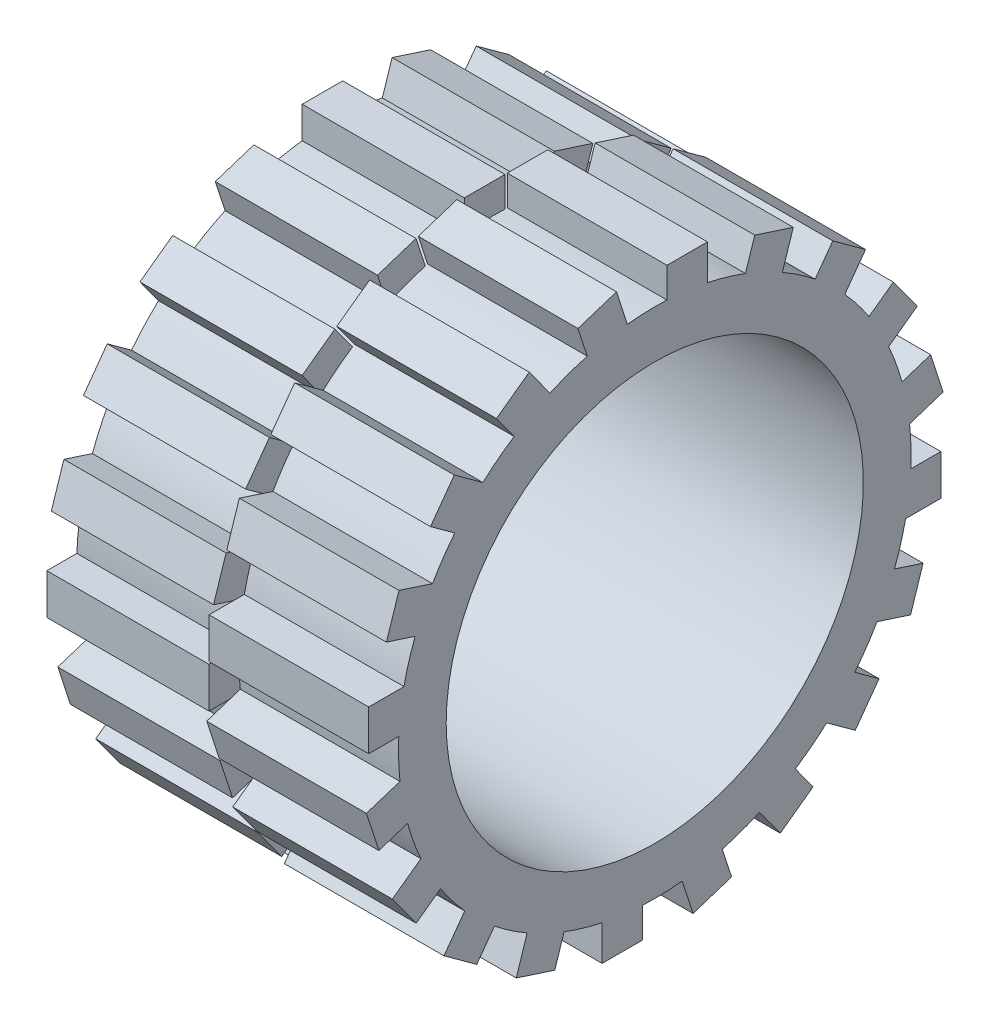
from build123d import *

# Parameters (mm, degrees)
SKETCH1_R           = 10.75
BOSS_EXTRUDE1_DEPTH = 13.5
SKETCH2_R           = 8.75
CUT_EXTRUDE1_DEPTH  = 21.331625611
SKETCH3_W           = 6.802910615
SKETCH3_H           = 1.7
SKETCH3_W_2         = 6.697089385
BOSS_EXTRUDE2_DEPTH = 2
CIRPATTERN1_COUNT   = 20
CUT_EXTRUDE5_DEPTH  = 5


with BuildPart() as part:
    # Sketch1 → Boss-Extrude1 (new body)
    with BuildSketch(Plane(origin=(0, 0, 0), x_dir=(0, 0, -1), z_dir=(1, 0, 0))):
        Circle(SKETCH1_R)
    extrude(amount=BOSS_EXTRUDE1_DEPTH)

    # Sketch2 → Cut-Extrude1 (cut, through all)
    with BuildSketch(Plane.ZY):
        Circle(SKETCH2_R)
    extrude(amount=-CUT_EXTRUDE1_DEPTH, mode=Mode.SUBTRACT)

    # Sketch3 → Boss-Extrude2 (add)
    with BuildSketch(Plane.XY.offset(10)):
        with Locations((3.401455308, -0.439203541)):
            Rectangle(SKETCH3_W, SKETCH3_H)
        with Locations((10.151455308, 1.360405179)):
            Rectangle(SKETCH3_W_2, SKETCH3_H)
    boss_extrude2 = extrude(amount=BOSS_EXTRUDE2_DEPTH)

    # CirPattern1: Boss-Extrude2 ×20 about axis
    cirpattern1_axis = Axis((0, 0, 0), (1, 0, 0))
    for i in range(1, CIRPATTERN1_COUNT):
        add(boss_extrude2.rotate(cirpattern1_axis, i * 360 / CIRPATTERN1_COUNT))

    # Sketch5 → Cut-Extrude5 (cut)
    with BuildSketch(Plane.ZY):
        with BuildLine():
            Line((-1.694575387, 9.717569944), (-1.763806157, 9.651944944))
            add(Edge.make_bspline(
                [(-1.763806157, 9.651944944), (-1.776333871, 9.663730023), (-1.801090568, 9.687019159), (-1.841451774, 9.717236272), (-1.883562422, 9.743121841), (-1.927202779, 9.764183445), (-1.971292121, 9.78098844), (-2.015245235, 9.792952819), (-2.058611272, 9.8005829), (-2.087454272, 9.801495338), (-2.101666733, 9.801944944)],
                knots=[0, 0, 0, 0, 1.08915593, 2.152340314, 3.188132944, 4.216796309, 5.218260357, 6.173443236, 7.099959455, 8, 8, 8, 8], degree=3))
            add(Edge.make_bspline(
                [(-2.101666733, 9.801944944), (-2.110387656, 9.801838588), (-2.127806884, 9.801626152), (-2.153681098, 9.798914783), (-2.179283948, 9.795015246), (-2.204567101, 9.789373049), (-2.229579718, 9.782222148), (-2.254234804, 9.773277315), (-2.278578353, 9.762848823), (-2.302381059, 9.750798473), (-2.325457189, 9.737560798), (-2.347251803, 9.722891173), (-2.36790382, 9.70725977), (-2.387025073, 9.690275233), (-2.404725549, 9.67209141), (-2.421426559, 9.65304656), (-2.436540721, 9.632620361), (-2.450192735, 9.611188629), (-2.462371437, 9.58912778), (-2.473122233, 9.566650154), (-2.482147199, 9.543830306), (-2.489287916, 9.5206396), (-2.495179227, 9.497257448), (-2.499323754, 9.473521949), (-2.50166034, 9.449407687), (-2.502064512, 9.43325982), (-2.502267695, 9.425142059)],
                knots=[0, 0, 0, 0, 1.02818874, 2.053710826, 3.065248034, 4.081641283, 5.106893873, 6.131558223, 7.173050175, 8.228653731, 9.27666206, 10.308777013, 11.325269123, 12.329503258, 13.32196095, 14.316845687, 15.314881793, 16.315733098, 17.311955233, 18.285320748, 19.252783886, 20.203351036, 21.145449891, 22.095197417, 23.042428769, 24, 24, 24, 24], degree=3))
            add(Edge.make_bspline(
                [(-2.502267695, 9.425142059), (-2.502073367, 9.416843849), (-2.501685243, 9.400270089), (-2.499201161, 9.37553447), (-2.494591042, 9.351166224), (-2.488427917, 9.327085275), (-2.480718564, 9.303250383), (-2.47110845, 9.27976488), (-2.459725867, 9.256629637), (-2.446550754, 9.234053107), (-2.432102873, 9.212061472), (-2.415917509, 9.191346167), (-2.398724788, 9.171631338), (-2.379898356, 9.153354713), (-2.360041902, 9.136027426), (-2.338562174, 9.120126863), (-2.315881542, 9.105346748), (-2.291965401, 9.091873357), (-2.267073257, 9.079836877), (-2.241550092, 9.069133589), (-2.215314368, 9.060318903), (-2.188503962, 9.053134819), (-2.161150835, 9.047246171), (-2.133116143, 9.043457819), (-2.104606018, 9.040708748), (-2.085387513, 9.040507747), (-2.075705195, 9.040406482)],
                knots=[0, 0, 0, 0, 0.93586088, 1.869166235, 2.799637598, 3.729985548, 4.670839027, 5.622275134, 6.589130586, 7.576015415, 8.568469353, 9.55398029, 10.53834874, 11.515998671, 12.510579167, 13.508179873, 14.527009472, 15.561807829, 16.601455013, 17.643573243, 18.680854198, 19.719860599, 20.772568776, 21.833555941, 22.908541556, 24, 24, 24, 24], degree=3))
            add(Edge.make_bspline(
                [(-2.075705195, 9.040406482), (-2.064036477, 9.040650402), (-2.041123054, 9.041129378), (-2.007440826, 9.044858024), (-1.975091465, 9.050681485), (-1.94416587, 9.059209858), (-1.914628121, 9.070087946), (-1.886369936, 9.083201046), (-1.859613796, 9.099052118), (-1.834279265, 9.116942541), (-1.810941703, 9.136874926), (-1.7898935, 9.158383501), (-1.771470374, 9.181363861), (-1.755397737, 9.205680656), (-1.742101226, 9.231535163), (-1.731187365, 9.258800679), (-1.722821661, 9.287489468), (-1.719387525, 9.30731303), (-1.71765231, 9.317329559)],
                knots=[0, 0, 0, 0, 1.13008108, 2.219097802, 3.278683437, 4.311054135, 5.322181354, 6.324827112, 7.324222904, 8.330512327, 9.32562643, 10.293043162, 11.24128371, 12.174520618, 13.111833804, 14.052305215, 15.015860969, 16, 16, 16, 16], degree=3))
            Line((-1.71765231, 9.317329559), (-2.01765231, 9.317329559))
            Line((-2.01765231, 9.317329559), (-2.01765231, 9.409637252))
            Line((-2.01765231, 9.409637252), (-1.63688308, 9.409637252))
            add(Edge.make_bspline(
                [(-1.63688308, 9.409637252), (-1.637321726, 9.392432469), (-1.638180237, 9.358759601), (-1.644202244, 9.30965296), (-1.65392649, 9.263271667), (-1.66721057, 9.219566877), (-1.684407071, 9.178600525), (-1.705331435, 9.140331017), (-1.730318552, 9.105005584), (-1.75847838, 9.072335841), (-1.790081226, 9.043194043), (-1.824273157, 9.017581088), (-1.861110663, 8.996006129), (-1.9005589, 8.978453388), (-1.942488725, 8.96475436), (-1.986997166, 8.955041669), (-2.034023863, 8.949222536), (-2.066253294, 8.948479038), (-2.082736445, 8.94809879)],
                knots=[0, 0, 0, 0, 1.140356446, 2.231883559, 3.274166699, 4.278491846, 5.25512956, 6.21435461, 7.1637429, 8.11826594, 9.068280886, 10.0076534, 10.945064095, 11.891975133, 12.864533718, 13.863980011, 14.907571808, 16, 16, 16, 16], degree=3))
            add(Edge.make_bspline(
                [(-2.082736445, 8.94809879), (-2.092896194, 8.948245136), (-2.112934494, 8.948533776), (-2.142529304, 8.950585094), (-2.171308121, 8.953742956), (-2.199266751, 8.958511702), (-2.226508039, 8.964352614), (-2.252895933, 8.971832055), (-2.278530952, 8.980489721), (-2.30345272, 8.99033718), (-2.327435032, 9.001747034), (-2.350584708, 9.014426656), (-2.373029711, 9.028310663), (-2.394617154, 9.043639166), (-2.415459514, 9.060297513), (-2.435422399, 9.078319092), (-2.454617568, 9.097648809), (-2.466641687, 9.11137484), (-2.472700387, 9.118291098)],
                knots=[0, 0, 0, 0, 1.107784379, 2.184907829, 3.233506516, 4.263428166, 5.276301166, 6.270063455, 7.25232949, 8.225834625, 9.190232166, 10.146266622, 11.1027726, 12.066435141, 13.031522626, 14.010570082, 14.99756817, 16, 16, 16, 16], degree=3))
            add(Edge.make_bspline(
                [(-2.472700387, 9.118291098), (-2.481491056, 9.129263551), (-2.498926476, 9.151026327), (-2.521369431, 9.185894884), (-2.54050122, 9.22199822), (-2.556024374, 9.259436839), (-2.568145596, 9.298175722), (-2.576838633, 9.338165368), (-2.581931936, 9.379457273), (-2.582665702, 9.40739977), (-2.583036926, 9.42153629)],
                knots=[0, 0, 0, 0, 1.023165419, 2.029347347, 3.013907458, 3.994755782, 4.975994455, 5.96558838, 6.970761222, 8, 8, 8, 8], degree=3))
            add(Edge.make_bspline(
                [(-2.583036926, 9.42153629), (-2.582900065, 9.432121898), (-2.582628082, 9.453158577), (-2.579330092, 9.484390456), (-2.574598298, 9.515067777), (-2.567643342, 9.545165463), (-2.558875731, 9.574703615), (-2.547933406, 9.603695949), (-2.53519329, 9.632159573), (-2.520385591, 9.659898567), (-2.50390673, 9.686544845), (-2.486022387, 9.711991137), (-2.466478604, 9.73577404), (-2.445594542, 9.758194749), (-2.42312103, 9.778971596), (-2.399268607, 9.798296938), (-2.37401889, 9.8161967), (-2.347292443, 9.832388944), (-2.319488182, 9.846933875), (-2.290672753, 9.859685386), (-2.260854953, 9.870223953), (-2.230258173, 9.879165782), (-2.198650816, 9.885778247), (-2.166262249, 9.890573638), (-2.132923649, 9.893854935), (-2.11038867, 9.89411883), (-2.098962407, 9.894252636)],
                knots=[0, 0, 0, 0, 1.008945113, 2.00506715, 2.99143336, 3.967273523, 4.948097931, 5.927297278, 6.919902385, 7.919676788, 8.923139349, 9.905703106, 10.883022732, 11.856032218, 12.825136022, 13.798837087, 14.781400844, 15.773989409, 16.776158564, 17.77167057, 18.775803737, 19.789618931, 20.80898985, 21.851988756, 22.910860228, 24, 24, 24, 24], degree=3))
            add(Edge.make_bspline(
                [(-2.098962407, 9.894252636), (-2.089644001, 9.894103624), (-2.071166698, 9.893808151), (-2.04367151, 9.891760098), (-2.016601306, 9.888513957), (-1.989915948, 9.884084212), (-1.963706311, 9.878050692), (-1.93789773, 9.870830561), (-1.912452792, 9.862424093), (-1.887451242, 9.852398389), (-1.862724973, 9.841018886), (-1.838136499, 9.82820972), (-1.813769836, 9.813751862), (-1.789582727, 9.797602381), (-1.765422649, 9.780038645), (-1.741671741, 9.760558319), (-1.717756698, 9.73992961), (-1.702379089, 9.725097049), (-1.694575387, 9.717569944)],
                knots=[0, 0, 0, 0, 0.985871117, 1.954866573, 2.915460327, 3.869826059, 4.81536089, 5.759505086, 6.70452669, 7.649098992, 8.607881297, 9.583363685, 10.581137262, 11.603961102, 12.659522466, 13.73993555, 14.853081303, 16, 16, 16, 16], degree=3))
        make_face()
        with BuildLine():
            Line((-1.498421541, 9.628868021), (-1.41765231, 9.628868021))
            Line((-1.41765231, 9.628868021), (-1.41765231, 9.532053117))
            add(Edge.make_bspline(
                [(-1.41765231, 9.532053117), (-1.411689487, 9.541067473), (-1.400285633, 9.558307358), (-1.38133088, 9.581108036), (-1.361915737, 9.599986191), (-1.34194726, 9.615029953), (-1.321278606, 9.626296183), (-1.30036339, 9.634548678), (-1.278872555, 9.639428559), (-1.264430917, 9.640080071), (-1.25719558, 9.640406482)],
                knots=[0, 0, 0, 0, 1.2804753, 2.448899062, 3.506932113, 4.484331642, 5.4025378, 6.288909075, 7.142734305, 8, 8, 8, 8], degree=3))
            add(Edge.make_bspline(
                [(-1.25719558, 9.640406482), (-1.251583096, 9.640100347), (-1.240035045, 9.639470454), (-1.222553808, 9.635044813), (-1.204542634, 9.627979036), (-1.192934592, 9.621334407), (-1.18688308, 9.617870425)],
                knots=[0, 0, 0, 0, 0.901110191, 1.854092781, 2.881294221, 4, 4, 4, 4], degree=3))
            Line((-1.18688308, 9.617870425), (-1.231234041, 9.547918502))
            add(Edge.make_bspline(
                [(-1.231234041, 9.547918502), (-1.235119218, 9.549651713), (-1.242494028, 9.55294168), (-1.253282345, 9.55683534), (-1.263228974, 9.559128004), (-1.269565889, 9.559475331), (-1.272520099, 9.559637252)],
                knots=[0, 0, 0, 0, 1.180555205, 2.24091978, 3.179933427, 4, 4, 4, 4], degree=3))
            add(Edge.make_bspline(
                [(-1.272520099, 9.559637252), (-1.279001573, 9.559205242), (-1.292221902, 9.558324068), (-1.311632202, 9.551396946), (-1.330467198, 9.540204741), (-1.345425625, 9.527792169), (-1.357007919, 9.515822736), (-1.365272548, 9.505370289), (-1.372853826, 9.49365007), (-1.380097597, 9.480862437), (-1.386697501, 9.466789048), (-1.392857273, 9.451570507), (-1.398426695, 9.435189189), (-1.401602472, 9.423776541), (-1.403229233, 9.417930521)],
                knots=[0, 0, 0, 0, 1.125678352, 2.296057538, 3.5422874, 4.923748041, 5.663163013, 6.437101912, 7.23742474, 8.08941207, 8.991984279, 9.93940061, 10.944477711, 12, 12, 12, 12], degree=3))
            add(Edge.make_bspline(
                [(-1.403229233, 9.417930521), (-1.404446135, 9.412716391), (-1.407141478, 9.401167488), (-1.409762159, 9.381792153), (-1.412351464, 9.358900355), (-1.414176309, 9.332428374), (-1.415867805, 9.302442317), (-1.416821826, 9.268896503), (-1.417619777, 9.231756498), (-1.417641137, 9.205791664), (-1.41765231, 9.192209367)],
                knots=[0, 0, 0, 0, 0.566838948, 1.255505196, 2.06880316, 3.007127437, 4.065329342, 5.249902469, 6.561414163, 8, 8, 8, 8], degree=3))
            Line((-1.41765231, 9.192209367), (-1.41765231, 8.971175713))
            Line((-1.41765231, 8.971175713), (-1.498421541, 8.971175713))
            Line((-1.498421541, 8.971175713), (-1.498421541, 9.628868021))
        make_face()
        with BuildLine():
            add(Edge.make_bspline(
                [(-0.78844558, 9.640406482), (-0.776104967, 9.64014371), (-0.75190804, 9.639628479), (-0.716471727, 9.634121773), (-0.682645835, 9.625701022), (-0.650300814, 9.614059764), (-0.619850909, 9.598455834), (-0.590852589, 9.579836301), (-0.563385359, 9.55777792), (-0.546922294, 9.540714417), (-0.538565772, 9.532053117)],
                knots=[0, 0, 0, 0, 1.054011418, 2.066658804, 3.057071809, 4.030435133, 4.997543892, 5.974964718, 6.972108034, 8, 8, 8, 8], degree=3))
            add(Edge.make_bspline(
                [(-0.538565772, 9.532053117), (-0.531370412, 9.523769521), (-0.517118943, 9.507362638), (-0.498844901, 9.480759767), (-0.483102214, 9.453209455), (-0.470486024, 9.424345857), (-0.460538447, 9.394420941), (-0.453475839, 9.363331853), (-0.449274913, 9.331147249), (-0.448708436, 9.309289119), (-0.448421541, 9.298218982)],
                knots=[0, 0, 0, 0, 1.025258237, 2.030674902, 3.01204498, 3.988269485, 4.97094183, 5.956517959, 6.965070386, 8, 8, 8, 8], degree=3))
            add(Edge.make_bspline(
                [(-0.448421541, 9.298218982), (-0.448673885, 9.287084682), (-0.449172528, 9.265082785), (-0.453889458, 9.232677805), (-0.461226023, 9.201256279), (-0.471725639, 9.170949758), (-0.485189153, 9.141665602), (-0.501618186, 9.113531718), (-0.521128031, 9.086492598), (-0.543243344, 9.06077784), (-0.567685255, 9.037077956), (-0.594200836, 9.016422115), (-0.622269016, 8.998725152), (-0.652263022, 8.984470074), (-0.683908947, 8.973230436), (-0.71727505, 8.965336146), (-0.752309497, 8.960563142), (-0.776230782, 8.959950223), (-0.78844558, 8.959637252)],
                knots=[0, 0, 0, 0, 0.998656419, 1.973391657, 2.932242238, 3.890759089, 4.846373663, 5.82037756, 6.809684879, 7.83454468, 8.860553229, 9.859544525, 10.845671541, 11.83227036, 12.833544569, 13.85385346, 14.904124723, 16, 16, 16, 16], degree=3))
            add(Edge.make_bspline(
                [(-0.78844558, 8.959637252), (-0.800720222, 8.959951274), (-0.824760729, 8.960566301), (-0.859918838, 8.965317603), (-0.89334474, 8.973226798), (-0.925032094, 8.98450701), (-0.955155055, 8.998725607), (-0.983385868, 9.016368613), (-1.009922989, 9.037084082), (-1.034370071, 9.06077618), (-1.056483998, 9.086493026), (-1.0759942, 9.113531607), (-1.092423141, 9.141665631), (-1.10588668, 9.17094975), (-1.116386289, 9.201256281), (-1.123722855, 9.232677804), (-1.128439785, 9.265082785), (-1.128938428, 9.287084682), (-1.129190772, 9.298218982)],
                knots=[0, 0, 0, 0, 1.099876186, 2.154163076, 3.173186993, 4.173200201, 5.163417411, 6.152872554, 7.150605724, 8.17532212, 9.198891216, 10.186952605, 11.159729845, 12.11414092, 13.071450619, 14.029093627, 15.002601286, 16, 16, 16, 16], degree=3))
            add(Edge.make_bspline(
                [(-1.129190772, 9.298218982), (-1.128901921, 9.309228951), (-1.128330045, 9.331026798), (-1.124133343, 9.363150899), (-1.117098285, 9.394187371), (-1.107138783, 9.423996779), (-1.094406306, 9.452733891), (-1.078884832, 9.480352276), (-1.060424383, 9.506834853), (-1.046229596, 9.523220531), (-1.039046541, 9.531512252)],
                knots=[0, 0, 0, 0, 1.031353054, 2.041901799, 3.029428768, 4.008703097, 4.981709435, 5.96992636, 6.972712378, 8, 8, 8, 8], degree=3))
            add(Edge.make_bspline(
                [(-1.039046541, 9.531512252), (-1.030702618, 9.540248665), (-1.014292824, 9.557430358), (-0.986688866, 9.579424436), (-0.957761883, 9.598431426), (-0.926975474, 9.61372531), (-0.894657024, 9.6257695), (-0.860657791, 9.63414349), (-0.825101229, 9.639608638), (-0.800785898, 9.640137884), (-0.78844558, 9.640406482)],
                knots=[0, 0, 0, 0, 1.027980169, 2.021703884, 2.998553061, 3.971491411, 4.943284454, 5.930300938, 6.949603206, 8, 8, 8, 8], degree=3))
        make_face()
        with BuildLine():
            add(Edge.make_bspline(
                [(-0.788806157, 9.559637252), (-0.797532971, 9.559389214), (-0.814761318, 9.558899541), (-0.84012064, 9.555175109), (-0.864533823, 9.549274322), (-0.888047182, 9.540890422), (-0.910581427, 9.53006499), (-0.93215813, 9.516768555), (-0.952840758, 9.501177223), (-0.972224717, 9.483315393), (-0.990014454, 9.463803652), (-1.005565934, 9.443014074), (-1.018789533, 9.421283871), (-1.029805574, 9.398590445), (-1.038010279, 9.374703824), (-1.043969056, 9.349894519), (-1.047689975, 9.324111983), (-1.048175044, 9.306584864), (-1.048421541, 9.297678117)],
                knots=[0, 0, 0, 0, 1.021534396, 2.016698045, 2.994645724, 3.958388632, 4.93408049, 5.916473867, 6.921342795, 7.962252576, 8.998418191, 10.008913653, 10.997312074, 11.973003931, 12.956656626, 13.948281152, 14.957379055, 16, 16, 16, 16], degree=3))
            add(Edge.make_bspline(
                [(-1.048421541, 9.297678117), (-1.048008358, 9.286170453), (-1.047188267, 9.263329892), (-1.040519206, 9.229692746), (-1.029362734, 9.197400269), (-1.014297433, 9.16664177), (-0.995421548, 9.138183184), (-0.973182017, 9.112810517), (-0.947817523, 9.090905594), (-0.919630423, 9.072730519), (-0.889196455, 9.058289439), (-0.856987687, 9.048055417), (-0.823394366, 9.041402696), (-0.800436463, 9.04074146), (-0.788806157, 9.040406482)],
                knots=[0, 0, 0, 0, 1.016792936, 2.018143844, 3.017858371, 4.030088057, 5.03801393, 6.028138512, 7.003788237, 7.991172063, 8.984598303, 9.972568034, 10.972917682, 12, 12, 12, 12], degree=3))
            add(Edge.make_bspline(
                [(-0.788806157, 9.040406482), (-0.777176519, 9.040743412), (-0.754219937, 9.041408501), (-0.720673292, 9.048021911), (-0.688552556, 9.058334281), (-0.658150199, 9.072714278), (-0.62997593, 9.090974613), (-0.604429013, 9.112686825), (-0.58237937, 9.138250386), (-0.563522157, 9.166679465), (-0.548210138, 9.197352584), (-0.537105886, 9.229698706), (-0.530420792, 9.263328374), (-0.529602865, 9.286169944), (-0.529190772, 9.297678117)],
                knots=[0, 0, 0, 0, 1.02726834, 2.027799167, 3.010890988, 4.004497153, 4.992059811, 5.971914811, 6.958719428, 7.966827853, 8.981595046, 9.981490638, 10.983022906, 12, 12, 12, 12], degree=3))
            add(Edge.make_bspline(
                [(-0.529190772, 9.297678117), (-0.529437184, 9.306584918), (-0.529922086, 9.324112141), (-0.53364422, 9.349893915), (-0.539598501, 9.37470604), (-0.547819774, 9.398582269), (-0.558787949, 9.421342628), (-0.572266553, 9.442950272), (-0.587754531, 9.463875669), (-0.605758934, 9.48325232), (-0.625122659, 9.501184186), (-0.645813669, 9.516774601), (-0.667358378, 9.530006554), (-0.689827156, 9.540983016), (-0.713343531, 9.549198046), (-0.737722507, 9.55520918), (-0.76297363, 9.558883802), (-0.780140241, 9.559384495), (-0.788806157, 9.559637252)],
                knots=[0, 0, 0, 0, 1.042956736, 2.052379634, 3.044323526, 4.02829302, 5.004299113, 5.996692471, 7.007513377, 8.048758398, 9.090003419, 10.095195979, 11.07790575, 12.047570684, 13.018257071, 13.989683339, 14.985167495, 16, 16, 16, 16], degree=3))
        make_face(mode=Mode.SUBTRACT)
        with BuildLine():
            Line((-0.298421541, 9.628868021), (-0.21765231, 9.628868021))
            Line((-0.21765231, 9.628868021), (-0.21765231, 9.323819944))
            add(Edge.make_bspline(
                [(-0.21765231, 9.323819944), (-0.217615821, 9.314865523), (-0.217546017, 9.297736134), (-0.217072632, 9.273087658), (-0.21595918, 9.250609075), (-0.214567053, 9.230287399), (-0.21277679, 9.21212607), (-0.210646783, 9.196188521), (-0.208266046, 9.182294017), (-0.205935634, 9.173925725), (-0.20485183, 9.170033886)],
                knots=[0, 0, 0, 0, 1.388932606, 2.656963016, 3.823490214, 4.879454478, 5.816252168, 6.653371382, 7.373723809, 8, 8, 8, 8], degree=3))
            add(Edge.make_bspline(
                [(-0.20485183, 9.170033886), (-0.20311317, 9.165142291), (-0.199671996, 9.155460795), (-0.193430243, 9.141475051), (-0.185708671, 9.128521407), (-0.177259001, 9.11610036), (-0.167513439, 9.104579849), (-0.156595289, 9.093979329), (-0.144870029, 9.083898277), (-0.127447308, 9.071970759), (-0.10362064, 9.059186817), (-0.072338503, 9.048156464), (-0.038420273, 9.041564396), (-0.014977917, 9.040799587), (-0.002928753, 9.040406482)],
                knots=[0, 0, 0, 0, 0.725840625, 1.436591201, 2.137033971, 2.831655856, 3.53531722, 4.242432219, 4.957935707, 5.694543706, 7.190802206, 8.724350549, 10.316345118, 12, 12, 12, 12], degree=3))
            add(Edge.make_bspline(
                [(-0.002928753, 9.040406482), (0.009119292, 9.040807946), (0.03243003, 9.041584705), (0.065975593, 9.047957615), (0.096640243, 9.058604792), (0.124116202, 9.073469555), (0.148278846, 9.091660371), (0.168414268, 9.113005493), (0.185027562, 9.136829621), (0.192281413, 9.154604436), (0.19592942, 9.163543502)],
                knots=[0, 0, 0, 0, 1.157059328, 2.238695713, 3.266970494, 4.264342957, 5.228770407, 6.160125903, 7.074715775, 8, 8, 8, 8], degree=3))
            add(Edge.make_bspline(
                [(0.19592942, 9.163543502), (0.197007937, 9.167134836), (0.199392273, 9.175074398), (0.20195402, 9.188543476), (0.204261739, 9.204605803), (0.20623227, 9.223366485), (0.207637598, 9.244776496), (0.208395147, 9.268829144), (0.209250989, 9.295448922), (0.209263979, 9.314083489), (0.209270767, 9.323819944)],
                knots=[0, 0, 0, 0, 0.557542046, 1.232589297, 2.036731608, 2.971723315, 4.038036528, 5.22795436, 6.551621927, 8, 8, 8, 8], degree=3))
            Line((0.209270767, 9.323819944), (0.209270767, 9.628868021))
            Line((0.209270767, 9.628868021), (0.290039997, 9.628868021))
            Line((0.290039997, 9.628868021), (0.290039997, 9.308675713))
            add(Edge.make_bspline(
                [(0.290039997, 9.308675713), (0.289926419, 9.297796726), (0.28970606, 9.276690003), (0.288289886, 9.246016946), (0.285859986, 9.217432369), (0.282171867, 9.190921141), (0.277834979, 9.166503503), (0.272240509, 9.14414816), (0.265560391, 9.123923989), (0.258024687, 9.105476103), (0.249121921, 9.088749759), (0.239652116, 9.072874835), (0.228717174, 9.058245223), (0.217204828, 9.044132673), (0.204398688, 9.031239137), (0.190538725, 9.019268758), (0.175820017, 9.00803855), (0.159915937, 8.997986507), (0.143058664, 8.988930798), (0.125227386, 8.980903806), (0.106203701, 8.974551715), (0.086233052, 8.96907183), (0.065217594, 8.964773823), (0.043177588, 8.961742992), (0.020120459, 8.959885049), (0.004406597, 8.959721238), (-0.003649907, 8.959637252)],
                knots=[0, 0, 0, 0, 1.493040784, 2.896703357, 4.213163133, 5.428574705, 6.569057535, 7.615249723, 8.588095153, 9.490268104, 10.346124644, 11.18633936, 12.024365274, 12.850166724, 13.684164916, 14.514361689, 15.362232829, 16.222528818, 17.093394965, 17.986930858, 18.902426812, 19.842810585, 20.827885679, 21.843828298, 22.894529745, 24, 24, 24, 24], degree=3))
            add(Edge.make_bspline(
                [(-0.003649907, 8.959637252), (-0.011646153, 8.959724605), (-0.027359522, 8.959896262), (-0.050417842, 8.961732727), (-0.072518912, 8.964769114), (-0.093584157, 8.969103313), (-0.113634717, 8.974513359), (-0.132751807, 8.98094284), (-0.15071158, 8.988934964), (-0.16772981, 8.997929193), (-0.183673281, 9.008103121), (-0.198615487, 9.019254902), (-0.212536392, 9.03136789), (-0.225439066, 9.044391496), (-0.237142403, 9.05848728), (-0.247792243, 9.073541852), (-0.257552538, 9.089406046), (-0.266386113, 9.106393717), (-0.27397485, 9.125055091), (-0.28067477, 9.145702916), (-0.286154649, 9.168563563), (-0.290614141, 9.193617487), (-0.294201654, 9.220744784), (-0.296692376, 9.250102376), (-0.298085018, 9.281618754), (-0.298306948, 9.303385869), (-0.298421541, 9.314625232)],
                knots=[0, 0, 0, 0, 1.083640291, 2.129454052, 3.13281866, 4.105697902, 5.042300162, 5.946461698, 6.836384745, 7.703652036, 8.553297018, 9.397182691, 10.228592656, 11.052265423, 11.879314572, 12.708807002, 13.549817954, 14.402308542, 15.300838682, 16.27712199, 17.341985831, 18.484375296, 19.725102775, 21.0496083, 22.476576903, 24, 24, 24, 24], degree=3))
            Line((-0.298421541, 9.314625232), (-0.298421541, 9.628868021))
        make_face()
        with BuildLine():
            Line((0.474655382, 9.628868021), (0.555424613, 9.628868021))
            Line((0.555424613, 9.628868021), (0.555424613, 9.507173309))
            add(Edge.make_bspline(
                [(0.555424613, 9.507173309), (0.564002251, 9.518214441), (0.580671176, 9.539670671), (0.609400437, 9.567439561), (0.639724474, 9.590858925), (0.672423637, 9.609214433), (0.706989729, 9.62305407), (0.743280896, 9.633283072), (0.78160515, 9.63931088), (0.807807095, 9.64003645), (0.821169805, 9.640406482)],
                knots=[0, 0, 0, 0, 1.0828784, 2.104357462, 3.088488658, 4.04616522, 5.001424249, 5.969181776, 6.964304535, 8, 8, 8, 8], degree=3))
            add(Edge.make_bspline(
                [(0.821169805, 9.640406482), (0.832841932, 9.640068808), (0.855912503, 9.639401376), (0.889871619, 9.634882591), (0.92257386, 9.627138041), (0.953834217, 9.615977806), (0.983987577, 9.602180685), (1.012587545, 9.584767733), (1.040079602, 9.564606141), (1.065772337, 9.541403588), (1.089512117, 9.516299177), (1.110043992, 9.489293441), (1.12775391, 9.461274491), (1.142069129, 9.431807953), (1.153282704, 9.401125865), (1.161257907, 9.369104266), (1.166004158, 9.335861881), (1.16664096, 9.313258325), (1.166963074, 9.301824752)],
                knots=[0, 0, 0, 0, 1.041296284, 2.058176809, 3.050446431, 4.034000596, 5.01514041, 6.003636468, 7.015969324, 8.052561599, 9.08815499, 10.094063707, 11.074456064, 12.040834395, 13.011057502, 13.983766392, 14.980127149, 16, 16, 16, 16], degree=3))
            add(Edge.make_bspline(
                [(1.166963074, 9.301824752), (1.166647949, 9.290149872), (1.166026478, 9.267125325), (1.161206333, 9.233314358), (1.153503137, 9.200789033), (1.142431033, 9.169603451), (1.128123222, 9.139779083), (1.110713477, 9.111337439), (1.090171243, 9.084287629), (1.06669381, 9.058996884), (1.041223055, 9.035699917), (1.013997415, 9.015324414), (0.985439406, 8.998213774), (0.955695134, 8.983921013), (0.92450997, 8.973148737), (0.892029413, 8.965378446), (0.858271147, 8.960586718), (0.835307993, 8.959956167), (0.823693843, 8.959637252)],
                knots=[0, 0, 0, 0, 1.038740735, 2.04854663, 3.033179607, 4.009277356, 4.987731542, 5.972001279, 6.972200261, 8.005528982, 9.039189865, 10.040446548, 11.026516639, 11.997840187, 12.972163198, 13.956796175, 14.96660207, 16, 16, 16, 16], degree=3))
            add(Edge.make_bspline(
                [(0.823693843, 8.959637252), (0.810623896, 8.959970202), (0.784806919, 8.960627877), (0.747058947, 8.967292868), (0.710730613, 8.977253795), (0.676224401, 8.991833536), (0.643266964, 9.010413526), (0.612044728, 9.033070436), (0.582391849, 9.059756882), (0.564543883, 9.080002206), (0.555424613, 9.090346386)],
                knots=[0, 0, 0, 0, 1.014726462, 2.004382257, 2.969841629, 3.936926163, 4.907207904, 5.903978561, 6.929055279, 8, 8, 8, 8], degree=3))
            Line((0.555424613, 9.090346386), (0.555424613, 8.728868021))
            Line((0.555424613, 8.728868021), (0.474655382, 8.728868021))
            Line((0.474655382, 8.728868021), (0.474655382, 9.628868021))
        make_face()
        with BuildLine():
            add(Edge.make_bspline(
                [(0.820448651, 9.559637252), (0.811299621, 9.559472614), (0.793287538, 9.559148484), (0.76688611, 9.55529804), (0.741455858, 9.549708336), (0.71725307, 9.541245275), (0.694045769, 9.530857009), (0.672012698, 9.517875921), (0.651169323, 9.502536833), (0.631568087, 9.485133574), (0.613860383, 9.465957225), (0.598184201, 9.445491789), (0.585016609, 9.423763181), (0.574087518, 9.400973802), (0.565770674, 9.376945015), (0.559867774, 9.351813669), (0.556157112, 9.325552257), (0.555671385, 9.307666427), (0.555424613, 9.298579559)],
                knots=[0, 0, 0, 0, 1.05670511, 2.080379991, 3.077984906, 4.06214886, 5.038337365, 6.01289324, 7.01187578, 8.025460281, 9.038092164, 10.024533457, 11.000252242, 11.969694649, 12.940728589, 13.933144304, 14.949937299, 16, 16, 16, 16], degree=3))
            add(Edge.make_bspline(
                [(0.555424613, 9.298579559), (0.55583369, 9.286651188), (0.556635107, 9.263282497), (0.56315043, 9.229138008), (0.573753784, 9.196827583), (0.588804024, 9.166623316), (0.607819115, 9.138856301), (0.630730069, 9.113993003), (0.657329583, 9.092189708), (0.687175432, 9.073824242), (0.719169694, 9.058913025), (0.752543214, 9.048237943), (0.786837041, 9.041662227), (0.81002318, 9.040827331), (0.82171067, 9.040406482)],
                knots=[0, 0, 0, 0, 1.03728447, 2.032128127, 3.01272805, 3.987917167, 4.958271349, 5.931593992, 6.91984656, 7.941419022, 8.973179163, 9.983609215, 10.983593296, 12, 12, 12, 12], degree=3))
            add(Edge.make_bspline(
                [(0.82171067, 9.040406482), (0.833162725, 9.040806694), (0.855892995, 9.041601041), (0.889362226, 9.048476575), (0.92188839, 9.058979581), (0.952791863, 9.074294896), (0.981803617, 9.093063768), (1.008001731, 9.115579205), (1.030889223, 9.141676619), (1.0503972, 9.170735948), (1.066116725, 9.201895333), (1.077927358, 9.234136261), (1.084743848, 9.267345084), (1.085709879, 9.289715925), (1.086193843, 9.300923309)],
                knots=[0, 0, 0, 0, 1.00104056, 1.986885549, 2.97790532, 3.984399681, 4.995088187, 5.994304198, 6.996462723, 8.023150851, 9.048424203, 10.043036403, 11.019596776, 12, 12, 12, 12], degree=3))
            add(Edge.make_bspline(
                [(1.086193843, 9.300923309), (1.085819769, 9.312200307), (1.085074535, 9.334666442), (1.077733868, 9.367776903), (1.066702445, 9.400148096), (1.050615832, 9.430881952), (1.031535505, 9.459881002), (1.008457706, 9.485480571), (0.98258497, 9.507895887), (0.953607756, 9.526414135), (0.92250879, 9.541144691), (0.889770668, 9.551914769), (0.855559456, 9.558388019), (0.832255202, 9.559217178), (0.820448651, 9.559637252)],
                knots=[0, 0, 0, 0, 0.983928682, 1.960191568, 2.949917689, 3.96440592, 4.982380491, 5.975291189, 6.965713506, 7.964880129, 8.970154049, 9.96478489, 10.968906225, 12, 12, 12, 12], degree=3))
        make_face(mode=Mode.SUBTRACT)
        with BuildLine():
            Line((2.03234769, 9.894252636), (2.094547209, 9.845394463))
            Line((2.094547209, 9.845394463), (1.856746728, 9.481752636))
            add(Edge.make_bspline(
                [(1.856746728, 9.481752636), (1.872579085, 9.4842762), (1.903461887, 9.489198698), (1.93472169, 9.490010741), (1.949955863, 9.490406482)],
                knots=[0, 0, 0, 0, 1.025318673, 2, 2, 2, 2], degree=3))
            add(Edge.make_bspline(
                [(1.949955863, 9.490406482), (1.959103076, 9.490160625), (1.977109093, 9.489676662), (2.003545128, 9.485952244), (2.028947997, 9.480082929), (2.053212412, 9.471527206), (2.076425464, 9.460598029), (2.098720366, 9.447499463), (2.119678026, 9.431555145), (2.139568329, 9.413744156), (2.157626726, 9.394016932), (2.173614854, 9.373085159), (2.187044601, 9.350970647), (2.197940752, 9.327684596), (2.206402006, 9.303262901), (2.212570258, 9.277736808), (2.216216439, 9.251088715), (2.216711565, 9.232965756), (2.216963074, 9.223759848)],
                knots=[0, 0, 0, 0, 1.04369286, 2.054478336, 3.041073146, 4.015093852, 4.984733326, 5.965804835, 6.960378782, 7.985147595, 9.009457201, 10.008161701, 10.986880575, 11.956520048, 12.937015923, 13.931873656, 14.949455224, 16, 16, 16, 16], degree=3))
            add(Edge.make_bspline(
                [(2.216963074, 9.223759848), (2.216597133, 9.211165067), (2.215877047, 9.186381518), (2.208701785, 9.150284651), (2.197552162, 9.11589629), (2.181615084, 9.083765474), (2.161819614, 9.053936242), (2.137679661, 9.027505694), (2.110051336, 9.003933399), (2.078811873, 8.984221697), (2.045192254, 8.968123769), (2.009873169, 8.956561278), (1.973197617, 8.949442672), (1.948305004, 8.948550231), (1.935713074, 8.94809879)],
                knots=[0, 0, 0, 0, 1.031375318, 2.029502543, 3.004789286, 3.987476834, 4.960371455, 5.9300674, 6.912260825, 7.929083631, 8.949397511, 9.960523116, 10.96833055, 12, 12, 12, 12], degree=3))
            add(Edge.make_bspline(
                [(1.935713074, 8.94809879), (1.923602494, 8.948491757), (1.899613555, 8.949270157), (1.864325122, 8.956204255), (1.830417489, 8.967443224), (1.79812822, 8.982926896), (1.768217205, 9.002484637), (1.74145747, 9.026029223), (1.717982442, 9.053057371), (1.698446111, 9.083564889), (1.682951009, 9.116348021), (1.671330742, 9.150531861), (1.664543137, 9.185991857), (1.663594651, 9.210029864), (1.66311692, 9.222137252)],
                knots=[0, 0, 0, 0, 1.012016664, 2.004627821, 2.994792927, 3.992885782, 4.990978636, 5.973936114, 6.964471063, 7.975201453, 8.993600317, 9.990122807, 10.98767138, 12, 12, 12, 12], degree=3))
            add(Edge.make_bspline(
                [(1.66311692, 9.222137252), (1.66342072, 9.231405859), (1.664041022, 9.250330584), (1.66837218, 9.278992762), (1.675331699, 9.308320183), (1.683125762, 9.333199833), (1.691360919, 9.353581367), (1.698214429, 9.370013693), (1.706744885, 9.386923684), (1.715840897, 9.40489119), (1.726321235, 9.423453158), (1.737716688, 9.442919816), (1.750342312, 9.462981569), (1.759193211, 9.476595791), (1.763717882, 9.483555521)],
                knots=[0, 0, 0, 0, 1.173818275, 2.396712641, 3.66331629, 4.989737886, 5.693666774, 6.447286557, 7.243889047, 8.091586357, 8.998013824, 9.943181721, 10.948533338, 12, 12, 12, 12], degree=3))
            Line((1.763717882, 9.483555521), (2.03234769, 9.894252636))
        make_face()
        with BuildLine():
            add(Edge.make_bspline(
                [(1.933008747, 9.39809879), (1.926152741, 9.397898722), (1.91276097, 9.39750793), (1.89311335, 9.39523858), (1.874518513, 9.390965106), (1.856730108, 9.385522335), (1.840080698, 9.378038691), (1.824449282, 9.368948228), (1.809775412, 9.358245639), (1.796212784, 9.346082548), (1.783916299, 9.332765625), (1.773326866, 9.318502034), (1.764192534, 9.303635524), (1.756765781, 9.288041882), (1.750982619, 9.271727068), (1.746799354, 9.254766118), (1.744471247, 9.237045296), (1.74408393, 9.225028367), (1.743886151, 9.218892059)],
                knots=[0, 0, 0, 0, 1.129588631, 2.206414736, 3.251139165, 4.268635594, 5.265702196, 6.250456724, 7.242448911, 8.251968645, 9.246821453, 10.222880186, 11.173611482, 12.116736599, 13.062300278, 14.020270554, 14.989073742, 16, 16, 16, 16], degree=3))
            add(Edge.make_bspline(
                [(1.743886151, 9.218892059), (1.744047216, 9.212810636), (1.744363039, 9.20088587), (1.747230778, 9.183312938), (1.751611228, 9.166401962), (1.75812733, 9.150240122), (1.765899958, 9.134581069), (1.776161327, 9.119991995), (1.787531358, 9.105586835), (1.801122369, 9.09247217), (1.815708377, 9.080269039), (1.831291543, 9.069602688), (1.847532676, 9.060477672), (1.864651041, 9.053326246), (1.882403769, 9.047457144), (1.900938768, 9.043327049), (1.920268931, 9.040992057), (1.933363144, 9.040604236), (1.940039997, 9.040406482)],
                knots=[0, 0, 0, 0, 0.989467248, 1.94019797, 2.891935182, 3.827694429, 4.772920941, 5.730924762, 6.725747692, 7.756678648, 8.79901574, 9.819492441, 10.826891316, 11.826466727, 12.835195252, 13.867842842, 14.912794438, 16, 16, 16, 16], degree=3))
            add(Edge.make_bspline(
                [(1.940039997, 9.040406482), (1.94671684, 9.040604251), (1.959811031, 9.040992103), (1.979141349, 9.043326875), (1.997675774, 9.047457784), (2.015430591, 9.053323925), (2.032541244, 9.060486282), (2.048768173, 9.069545919), (2.064203968, 9.080334635), (2.078799551, 9.092451316), (2.092333992, 9.105661478), (2.103976721, 9.119863407), (2.113923838, 9.13469898), (2.122006915, 9.150178437), (2.128451247, 9.166411734), (2.13285391, 9.18331032), (2.135715727, 9.200886555), (2.136032364, 9.212810867), (2.136193843, 9.218892059)],
                knots=[0, 0, 0, 0, 1.087397944, 2.132534446, 3.165364764, 4.174271784, 5.174024072, 6.181601208, 7.194203697, 8.236725232, 9.267838612, 10.269026844, 11.221737037, 12.171628256, 13.107553087, 14.05945871, 15.010357665, 16, 16, 16, 16], degree=3))
            add(Edge.make_bspline(
                [(2.136193843, 9.218892059), (2.13605234, 9.225036372), (2.135774613, 9.237095661), (2.132633369, 9.254758191), (2.128276759, 9.271813244), (2.121698265, 9.288153631), (2.113151725, 9.30371487), (2.102741706, 9.318575567), (2.090699045, 9.332849656), (2.07678825, 9.346108664), (2.061645047, 9.358232198), (2.045543896, 9.36893437), (2.028698988, 9.377966507), (2.011127403, 9.385502619), (1.992627805, 9.390941055), (1.973498861, 9.395223318), (1.953495912, 9.397502122), (1.939924785, 9.397897368), (1.933008747, 9.39809879)],
                knots=[0, 0, 0, 0, 0.978206639, 1.919901502, 2.851605144, 3.780102724, 4.718870031, 5.675451981, 6.667674623, 7.690630536, 8.733308323, 9.756129687, 10.767539656, 11.776269907, 12.797430371, 13.836405707, 14.897401972, 16, 16, 16, 16], degree=3))
        make_face(mode=Mode.SUBTRACT)
        with BuildLine():
            Line((2.505424613, 8.94809879), (2.440881343, 8.992990617))
            Line((2.440881343, 8.992990617), (2.691121728, 9.358795906))
            add(Edge.make_bspline(
                [(2.691121728, 9.358795906), (2.675155539, 9.356843404), (2.643717222, 9.352998818), (2.612053396, 9.352292536), (2.596470286, 9.351944944)],
                knots=[0, 0, 0, 0, 1.015715272, 2, 2, 2, 2], degree=3))
            add(Edge.make_bspline(
                [(2.596470286, 9.351944944), (2.587022331, 9.352186935), (2.568476821, 9.352661942), (2.541211539, 9.356426979), (2.515012395, 9.362225583), (2.489948846, 9.37087812), (2.465926688, 9.381631374), (2.442998361, 9.394966035), (2.421194732, 9.410653367), (2.40074997, 9.428610422), (2.382155523, 9.448327635), (2.365589532, 9.469196229), (2.351821812, 9.491458621), (2.340384976, 9.514660678), (2.331711431, 9.539135882), (2.32539535, 9.564605728), (2.321506744, 9.591248722), (2.32104412, 9.609383755), (2.320809228, 9.618591579)],
                knots=[0, 0, 0, 0, 1.060718605, 2.082097864, 3.085795603, 4.069760067, 5.054557537, 6.03741023, 7.043284206, 8.066802108, 9.088538119, 10.083643548, 11.053783639, 12.022749082, 12.983451788, 13.964007469, 14.966251758, 16, 16, 16, 16], degree=3))
            add(Edge.make_bspline(
                [(2.320809228, 9.618591579), (2.321255226, 9.631183518), (2.322130628, 9.65589894), (2.329175961, 9.692010481), (2.340762906, 9.726155592), (2.356918774, 9.758244499), (2.377267702, 9.787815603), (2.401724197, 9.814457817), (2.430139502, 9.837792208), (2.461866307, 9.8578504), (2.496157084, 9.873982256), (2.532071881, 9.885872362), (2.569335512, 9.892866326), (2.594578628, 9.893788404), (2.607287593, 9.894252636)],
                knots=[0, 0, 0, 0, 1.022988612, 2.007919123, 2.978103895, 3.94594894, 4.918897164, 5.887013414, 6.875921846, 7.89917871, 8.930658928, 9.948724884, 10.967259574, 12, 12, 12, 12], degree=3))
            add(Edge.make_bspline(
                [(2.607287593, 9.894252636), (2.619756044, 9.893782023), (2.644392528, 9.892852135), (2.680621129, 9.886041972), (2.715320248, 9.87456397), (2.74829753, 9.858702225), (2.778830522, 9.838819706), (2.806287159, 9.815127971), (2.830040869, 9.787612264), (2.850052724, 9.756938081), (2.866116449, 9.723980858), (2.877706465, 9.689579278), (2.884841057, 9.653980749), (2.885740113, 9.62986217), (2.886193843, 9.617690136)],
                knots=[0, 0, 0, 0, 1.026385292, 2.028040595, 3.023318987, 4.028184125, 5.03290303, 6.015178782, 7.004435299, 8.016004309, 9.023023918, 10.015172535, 10.998308025, 12, 12, 12, 12], degree=3))
            add(Edge.make_bspline(
                [(2.886193843, 9.617690136), (2.885890824, 9.608241739), (2.885276225, 9.589078029), (2.880972603, 9.559961655), (2.873664555, 9.530274196), (2.865371261, 9.505145785), (2.857365847, 9.484392184), (2.84983127, 9.467998921), (2.841471002, 9.45074431), (2.831720462, 9.43280928), (2.821238729, 9.4139652), (2.809394915, 9.394401073), (2.796459197, 9.374090646), (2.78724584, 9.360398538), (2.782527978, 9.353387252)],
                knots=[0, 0, 0, 0, 1.179839688, 2.393009684, 3.667231171, 4.993948276, 5.694988576, 6.444077775, 7.246288328, 8.089075292, 8.993003841, 9.939041771, 10.944649915, 12, 12, 12, 12], degree=3))
            Line((2.782527978, 9.353387252), (2.505424613, 8.94809879))
        make_face()
        with BuildLine():
            add(Edge.make_bspline(
                [(2.611434228, 9.444252636), (2.618591546, 9.444448164), (2.632524411, 9.444828789), (2.652935716, 9.447145451), (2.67220194, 9.451253047), (2.690374547, 9.457146688), (2.70763575, 9.464258402), (2.723711378, 9.473312913), (2.738614883, 9.484117191), (2.752446064, 9.496256909), (2.764728235, 9.509744202), (2.775667872, 9.523860601), (2.784966303, 9.538668072), (2.792311146, 9.554352054), (2.798350037, 9.570530764), (2.802520383, 9.587464741), (2.80483064, 9.605065759), (2.805224473, 9.617022556), (2.805424613, 9.62309879)],
                knots=[0, 0, 0, 0, 1.163407946, 2.26475976, 3.333800367, 4.359385343, 5.366239384, 6.363380779, 7.350133999, 8.353570782, 9.349036268, 10.310270964, 11.253520213, 12.184142, 13.120487599, 14.056272588, 15.012232024, 16, 16, 16, 16], degree=3))
            add(Edge.make_bspline(
                [(2.805424613, 9.62309879), (2.805252412, 9.629177561), (2.80491307, 9.641156525), (2.802190621, 9.658783601), (2.797401278, 9.675676154), (2.790975153, 9.691926665), (2.782509949, 9.707401617), (2.77235191, 9.722295299), (2.760283566, 9.736513274), (2.746397192, 9.749721156), (2.731422592, 9.76189633), (2.715464178, 9.772641321), (2.698653485, 9.781646771), (2.681093074, 9.789077935), (2.662746355, 9.794876963), (2.643624187, 9.799047143), (2.62362994, 9.801354165), (2.610057609, 9.801745509), (2.603140959, 9.801944944)],
                knots=[0, 0, 0, 0, 0.972161553, 1.915763587, 2.844109794, 3.775983486, 4.705125789, 5.659731448, 6.655561913, 7.682237399, 8.721216875, 9.739758359, 10.754845918, 11.767244016, 12.7857855, 13.828538656, 14.893392813, 16, 16, 16, 16], degree=3))
            add(Edge.make_bspline(
                [(2.603140959, 9.801944944), (2.596284462, 9.801745187), (2.582832072, 9.801353266), (2.563015574, 9.799051528), (2.544022703, 9.794848918), (2.525729143, 9.789080621), (2.508169253, 9.781646217), (2.491359353, 9.772640849), (2.475397206, 9.761898803), (2.460436964, 9.749711576), (2.446526069, 9.736574753), (2.434665219, 9.722233014), (2.424483933, 9.707409365), (2.41603036, 9.691924605), (2.409601142, 9.675676703), (2.404812627, 9.658783452), (2.402089956, 9.641156564), (2.401750644, 9.629177574), (2.401578459, 9.62309879)],
                knots=[0, 0, 0, 0, 1.099389452, 2.15699305, 3.192601482, 4.213358962, 5.227959689, 6.245255729, 7.266013209, 8.307253147, 9.336162325, 10.327954924, 11.284637477, 12.215801273, 13.149702402, 14.080068371, 15.025723358, 16, 16, 16, 16], degree=3))
            add(Edge.make_bspline(
                [(2.401578459, 9.62309879), (2.401734268, 9.617017825), (2.402041553, 9.605025048), (2.405005842, 9.587403976), (2.409963114, 9.570512726), (2.416602386, 9.554187058), (2.425345652, 9.538585723), (2.436074641, 9.523782687), (2.448650353, 9.509610143), (2.462904679, 9.496288288), (2.478505063, 9.484060586), (2.495167083, 9.473381345), (2.512603899, 9.464362717), (2.530876889, 9.457126361), (2.549850638, 9.451311933), (2.569695672, 9.447153021), (2.590346361, 9.44485101), (2.6043375, 9.444454008), (2.611434228, 9.444252636)],
                knots=[0, 0, 0, 0, 0.952633368, 1.87876736, 2.791047057, 3.707742249, 4.635551637, 5.587206343, 6.568248508, 7.601284464, 8.641511608, 9.671105535, 10.699146789, 11.713763218, 12.747829548, 13.806491675, 14.887386225, 16, 16, 16, 16], degree=3))
        make_face(mode=Mode.SUBTRACT)
    extrude(amount=-CUT_EXTRUDE5_DEPTH, mode=Mode.SUBTRACT)


solid = part.part
